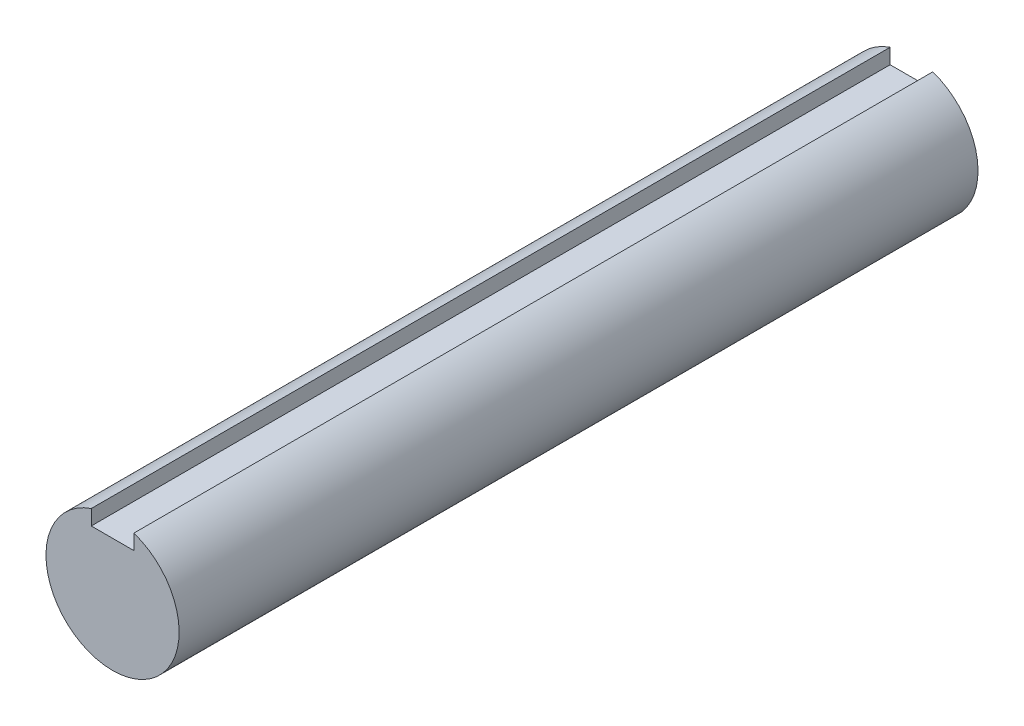
from build123d import *

# Parameters (mm, degrees)
BOSS_EXTRUDE1_DEPTH = 150


with BuildPart() as part:
    # Sketch1 → Boss-Extrude1 (new body)
    with BuildSketch(Plane.XY):
        with BuildLine():
            Line((4, 9), (-4, 9))
            Line((-4, 9), (-4, 11.842719282))
            ThreePointArc((-4, 11.842719282), (-7.288689869, -10.155048006), (12.5, 0))
            ThreePointArc((12.5, 0), (10.155048006, 7.288689869), (4, 11.842719282))
            Line((4, 11.842719282), (4, 9))
        make_face()
    extrude(amount=BOSS_EXTRUDE1_DEPTH)


solid = part.part
